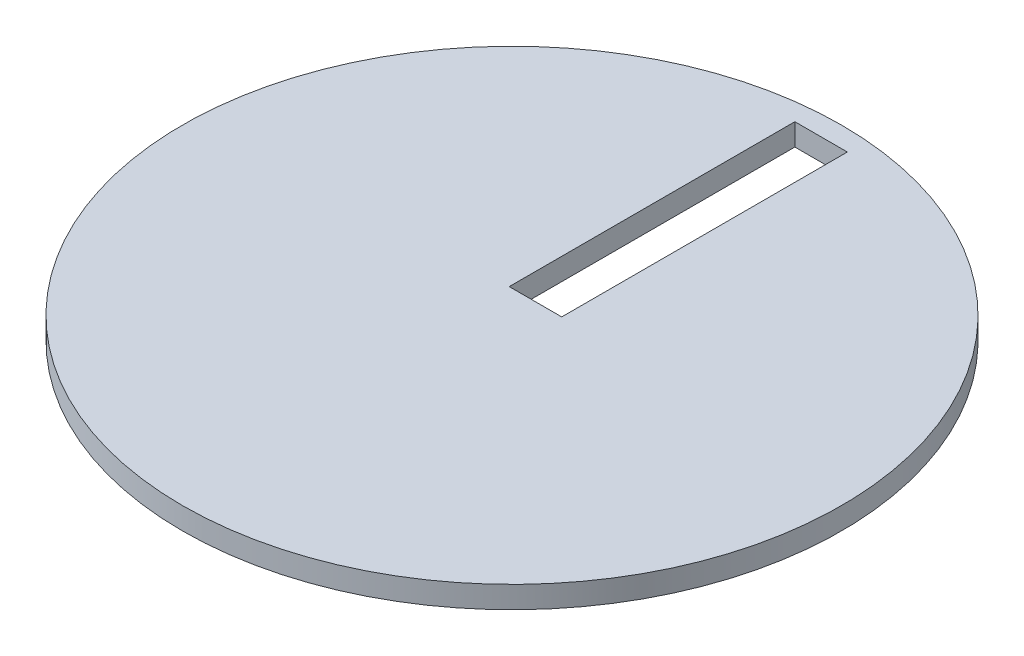
from build123d import *

# Parameters (mm, degrees)
SKETCH1_R           = 150
BOSS_EXTRUDE1_DEPTH = 10
SKETCH2_W           = 23.890989192
SKETCH2_H           = 130
CUT_EXTRUDE1_DEPTH  = 10


with BuildPart() as part:
    # Sketch1 → Boss-Extrude1 (new body)
    with BuildSketch(Plane(origin=(0, 0, 0), x_dir=(1, 0, 0), z_dir=(0, 1, 0))):
        Circle(SKETCH1_R)
    extrude(amount=BOSS_EXTRUDE1_DEPTH)

    # Sketch2 → Cut-Extrude1 (cut)
    with BuildSketch(Plane(origin=(0, 10, 0), x_dir=(1, 0, 0), z_dir=(0, 1, 0))):
        with Locations((0, 75.688074112)):
            Rectangle(SKETCH2_W, SKETCH2_H)
    extrude(amount=-CUT_EXTRUDE1_DEPTH, mode=Mode.SUBTRACT)


solid = part.part
